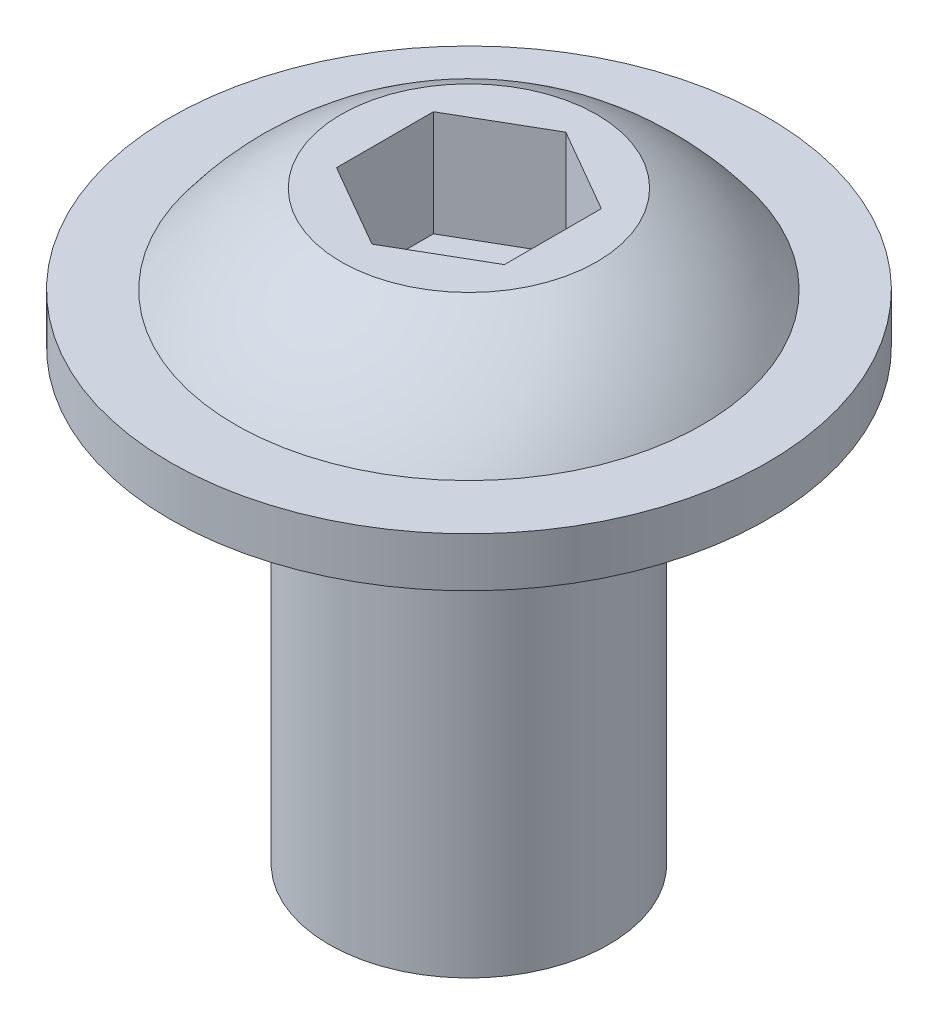
from build123d import *

# Parameters (mm, degrees)
SKETCH1_R           = 3.96875
BOSS_EXTRUDE1_DEPTH = 12.7
SKETCH2_R           = 8.475
BOSS_EXTRUDE2_DEPTH = 1.4
CUT_EXTRUDE1_DEPTH  = 3


with BuildPart() as part:
    # Sketch1 → Boss-Extrude1 (new body)
    with BuildSketch(Plane(origin=(0, 0, 0), x_dir=(1, 0, 0), z_dir=(0, 1, 0))):
        Circle(SKETCH1_R)
    extrude(amount=BOSS_EXTRUDE1_DEPTH)

    # Sketch2 → Boss-Extrude2 (add)
    with BuildSketch(Plane(origin=(0, 12.7, 0), x_dir=(1, 0, 0), z_dir=(0, 1, 0))):
        Circle(SKETCH2_R)
    extrude(amount=BOSS_EXTRUDE2_DEPTH)

    # Sketch3 → Revolve2 (revolve)
    with BuildSketch(Plane.XY):
        with BuildLine():
            Line((-3.625, 16.6), (0, 16.6))
            Line((0, 16.6), (0, 14.1))
            Line((0, 14.1), (-6.625, 14.1))
            ThreePointArc((-6.625, 14.1), (-5.275236962, 15.530284354), (-3.625, 16.6))
        make_face()
    revolve(axis=Axis((0, 16.6, 0), (0, -1, 0)))

    # Sketch4 → Cut-Extrude1 (cut)
    with BuildSketch(Plane(origin=(0, 16.6, 0), x_dir=(1, 0, 0), z_dir=(0, 1, 0))):
        Polygon((-2.38125, 1.374815329), (-2.38125, -1.374815329), (0, -2.749630657), (2.38125, -1.374815329), (2.38125, 1.374815329), (0, 2.749630657), align=None)
    extrude(amount=-CUT_EXTRUDE1_DEPTH, mode=Mode.SUBTRACT)


solid = part.part
